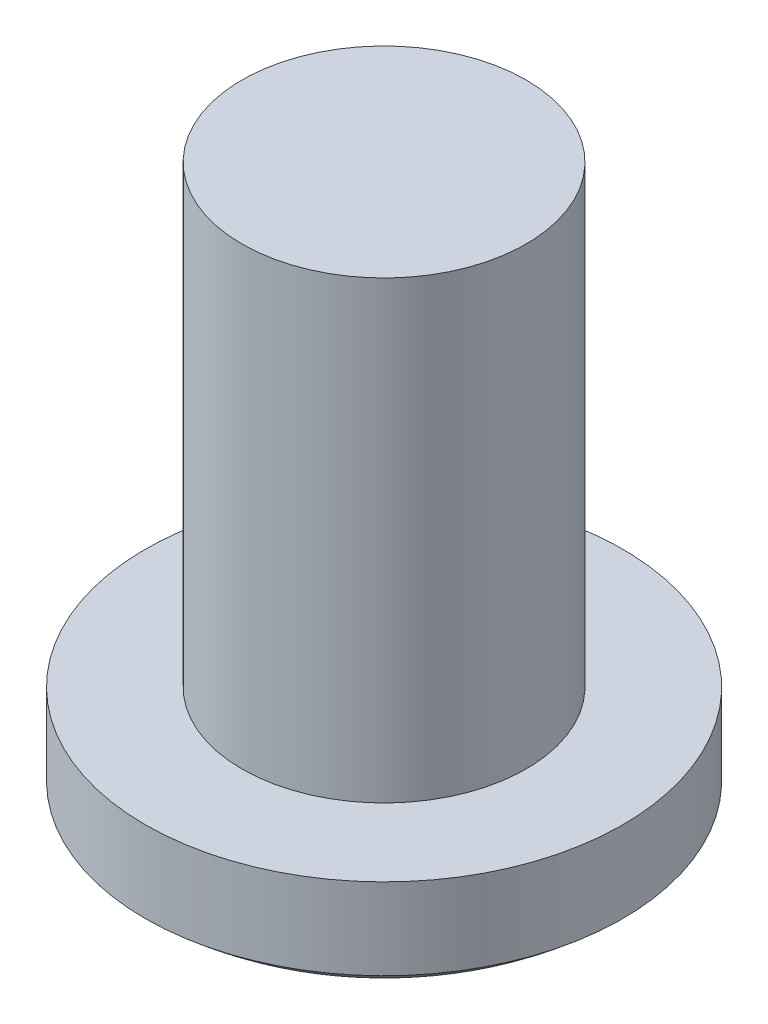
from build123d import *

# Parameters (mm, degrees)
SKETCH_1_R          = 4.2
EXTRUDE_1_DEPTH     = 2.9
SKETCH_2_R          = 2.5
EXTRUDE_2_DEPTH     = 8
CUT_EXTRUDE_1_DEPTH = 6.4


with BuildPart() as part:
    # 草图1 → 凸台-拉伸1 (new body)
    with BuildSketch(Plane(origin=(0, 0, 0), x_dir=(1, 0, 0), z_dir=(0, 1, 0))):
        Circle(SKETCH_1_R)
    extrude(amount=EXTRUDE_1_DEPTH)

    # 草图2 → 凸台-拉伸2 (add)
    with BuildSketch(Plane(origin=(0, 2.9, 0), x_dir=(1, 0, 0), z_dir=(0, 1, 0))):
        Circle(SKETCH_2_R)
    extrude(amount=EXTRUDE_2_DEPTH)

    # 草图3 one side → 切除-旋转1 (revolve, cut)
    with BuildSketch(Plane(origin=(0, 0, 0), x_dir=(0, 0, -1), z_dir=(1, 0, 0))):
        with BuildLine():
            ThreePointArc((0, 0), (-2.24147848, 0.330353936), (-4.2, 1.469455754))
            Line((-4.2, 1.469455754), (-5.100943616, -0.95254451))
            Line((-5.100943616, -0.95254451), (0, -0.95254451))
            Line((0, -0.95254451), (0, 0))
        make_face()
    revolve(axis=Axis((0, 1.035939113, 0), (0, -1, 0)), mode=Mode.SUBTRACT)

    # 草图4 → 切除-拉伸1 (cut)
    with BuildSketch(Plane(origin=(0, -5, 0), x_dir=(1, 0, 0), z_dir=(0, 1, 0))):
        Polygon((0.4, -2.5), (0.4, -0.4), (2.5, -0.4), (2.5, 0.4), (0.4, 0.4), (0.4, 2.5), (-0.4, 2.5), (-0.4, 0.4), (-2.5, 0.4), (-2.5, -0.4), (-0.4, -0.4), (-0.4, -2.5), align=None)
    extrude(amount=CUT_EXTRUDE_1_DEPTH, mode=Mode.SUBTRACT)


solid = part.part
